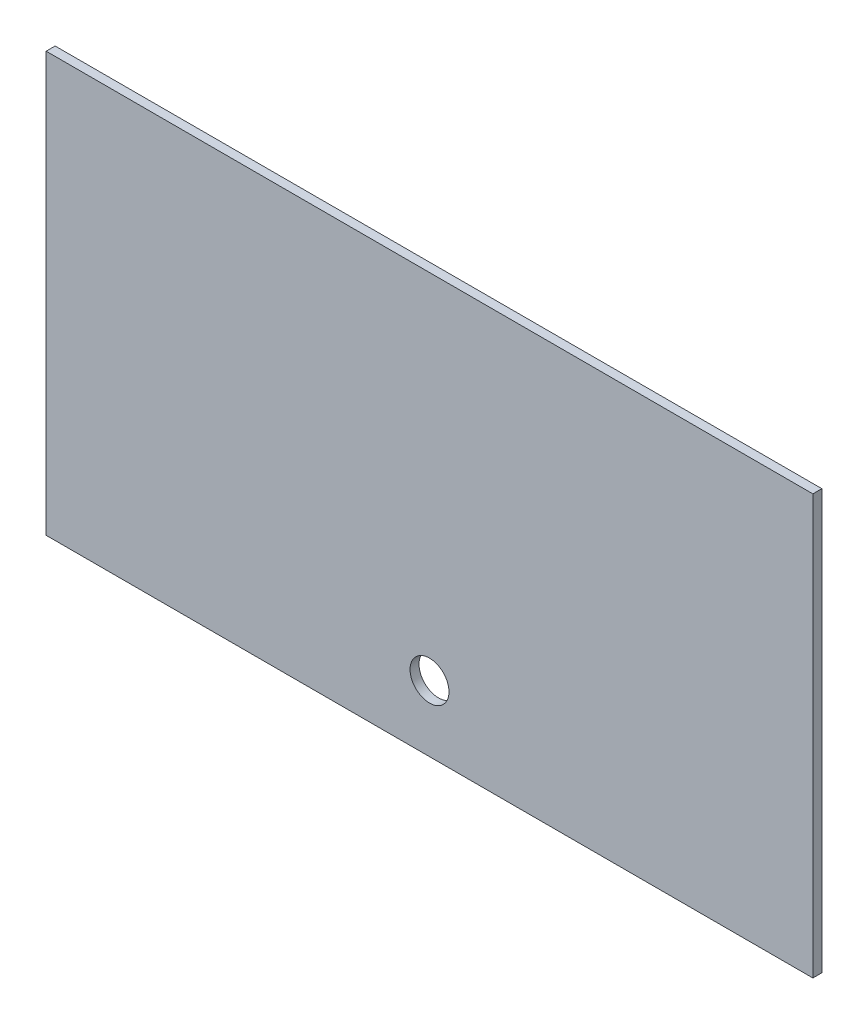
from build123d import *

# Parameters (mm, degrees)
SKETCH1_W           = 128
SKETCH1_H           = 70
BOSS_EXTRUDE1_DEPTH = 1.5
SKETCH3_R           = 3.25
CUT_EXTRUDE1_DEPTH  = 2.5


with BuildPart() as part:
    # Sketch1 → Boss-Extrude1 (new body)
    with BuildSketch(Plane.XY):
        Rectangle(SKETCH1_W, SKETCH1_H)
    extrude(amount=BOSS_EXTRUDE1_DEPTH)

    # Sketch3 → Cut-Extrude1 (cut, through all)
    with BuildSketch(Plane(origin=(0, 0, 0), x_dir=(-1, 0, 0), z_dir=(0, 0, -1))):
        with Locations((0, -24)):
            Circle(SKETCH3_R)
    extrude(amount=-CUT_EXTRUDE1_DEPTH, mode=Mode.SUBTRACT)


solid = part.part
